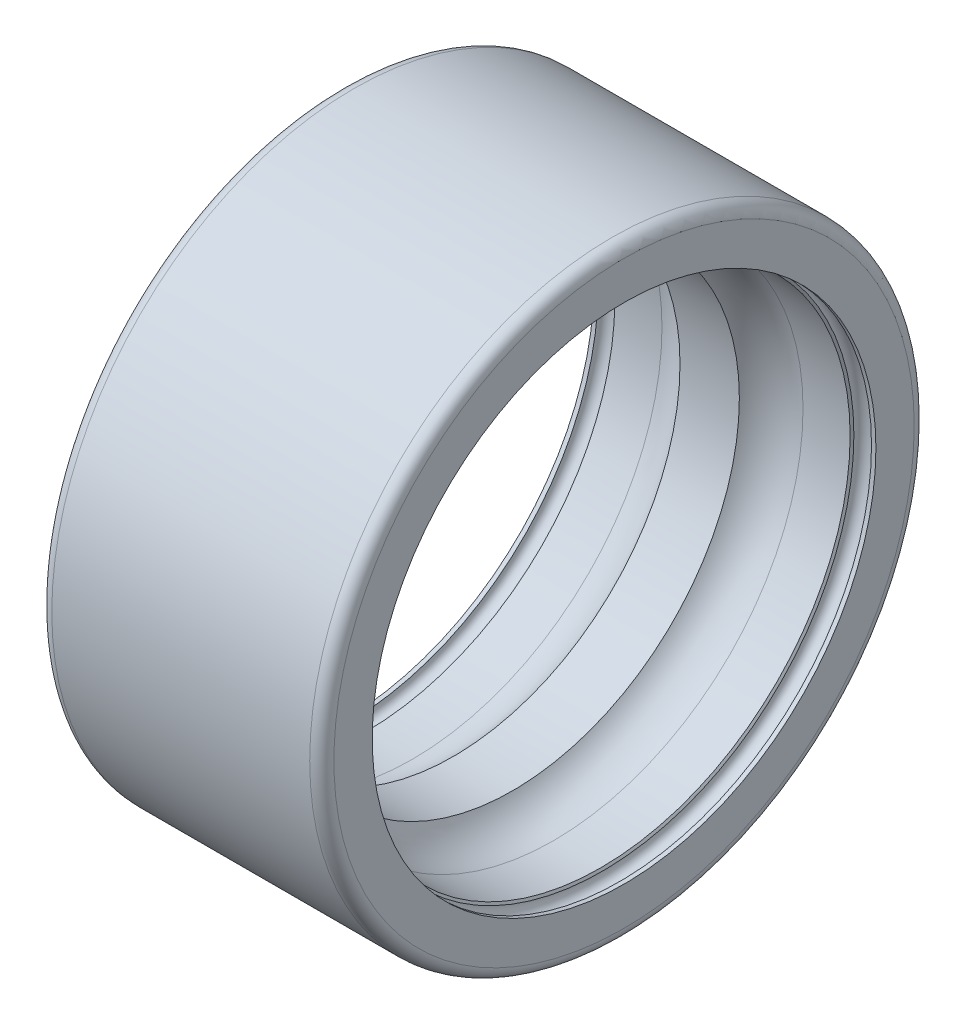
from build123d import *


with BuildPart() as part:
    # Sketch1 → Revolve1 (revolve)
    with BuildSketch(Plane(origin=(0, 0, 0), x_dir=(-1, 0, 0), z_dir=(0, 1, 0))):
        with BuildLine():
            Line((0, -12.5), (-0.21875, -12.5))
            ThreePointArc((-0.21875, -12.5), (-0.65625, -12.9375), (-1.09375, -12.5))
            Line((-1.09375, -12.5), (-1.161877332, -12.382))
            Line((-1.161877332, -12.382), (-3.5, -12.382))
            ThreePointArc((-3.5, -12.382), (-4.661125316, -12.079834609), (-5.527664667, -11.25))
            Line((-5.527664667, -11.25), (-8.472335333, -11.25))
            ThreePointArc((-8.472335333, -11.25), (-9.338874684, -12.079834609), (-10.5, -12.382))
            Line((-10.5, -12.382), (-12.838122668, -12.382))
            Line((-12.838122668, -12.382), (-12.90625, -12.5))
            ThreePointArc((-12.90625, -12.5), (-13.34375, -12.9375), (-13.78125, -12.5))
            Line((-13.78125, -12.5), (-14, -12.5))
            Line((-14, -12.5), (-14, -14.4))
            ThreePointArc((-14, -14.4), (-13.824264069, -14.824264069), (-13.4, -15))
            Line((-13.4, -15), (-0.6, -15))
            ThreePointArc((-0.6, -15), (-0.175735931, -14.824264069), (0, -14.4))
            Line((0, -14.4), (0, -12.5))
        make_face()
    revolve(axis=Axis((14, 0, 0), (-1, 0, 0)))


solid = part.part
